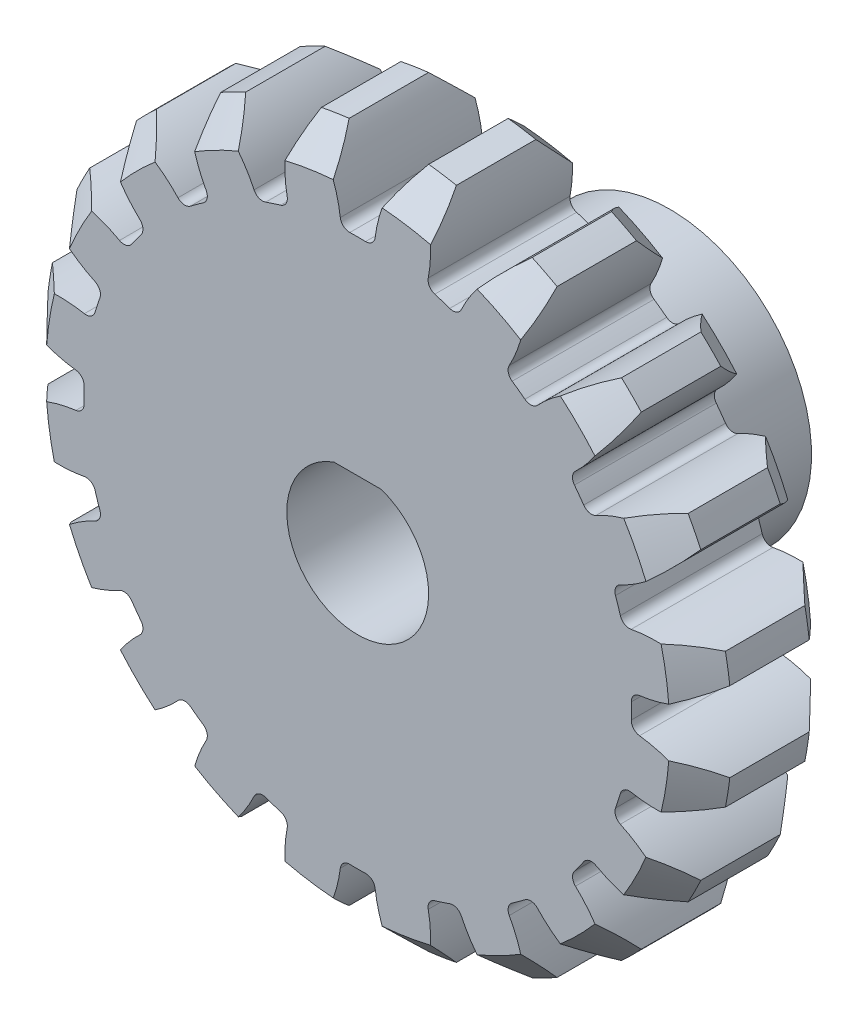
from build123d import *

# Parameters (mm, degrees)
SKETCH1_R                = 24.2
BOSS_EXTRUDE1_DEPTH      = 5
CUT_EXTRUDE1_DEPTH       = 6
FILLET1_R                = 0.66
CHAMFER1_SIZE            = 2.2
CIRPATTERN1_COUNT        = 20
FILLET1_OF_CIRPATTERN1_R = 0.66
CUT_EXTRUDE2_DEPTH       = 11.0000001
FILLET2_R                = 0.2
SKETCH6_R                = 10
BOSS_EXTRUDE2_DEPTH      = 12
BOSS_EXTRUDE2_DEPTH_BACK = 10
SKETCH8_R                = 1.15
CUT_EXTRUDE3_DEPTH       = 12


with BuildPart() as part:
    # Sketch1 → Boss-Extrude1 (new body, symmetric)
    with BuildSketch(Plane.XY):
        Circle(SKETCH1_R)
    extrude(amount=BOSS_EXTRUDE1_DEPTH, both=True)

    # Sketch2 → Cut-Extrude1 (cut, symmetric)
    with BuildSketch(Plane.XY):
        with BuildLine():
            ThreePointArc((2.806060396, 24.03676403), (1.665729243, 21.761247794), (1.171675149, 19.264401816))
            ThreePointArc((1.171675149, 19.264401816), (0, 19.3), (-1.171675149, 19.264401816))
            ThreePointArc((-1.171675149, 19.264401816), (-1.665729243, 21.761247794), (-2.806060396, 24.03676403))
            ThreePointArc((-2.806060396, 24.03676403), (0, 24.2), (2.806060396, 24.03676403))
        make_face()
    cut_extrude1 = extrude(amount=CUT_EXTRUDE1_DEPTH, both=True, mode=Mode.SUBTRACT)

    # Fillet1
    fillet1_edges = [part.edges().sort_by_distance(p)[0] for p in [
        (1.171675149, 19.264401816, 0),
        (-1.171675149, 19.264401816, 0),
    ]]
    fillet(fillet1_edges, radius=FILLET1_R)

    # Chamfer1
    chamfer1_edges = [part.edges().sort_by_distance(p)[0] for p in [
        (0, -24.2, -5),
        (0, -24.2, 5),
    ]]
    chamfer(chamfer1_edges, length=CHAMFER1_SIZE)

    # CirPattern1: Cut-Extrude1 ×20 about axis
    cirpattern1_axis = Axis((0, 0, 0), (0, 0, 1))
    for i in range(1, CIRPATTERN1_COUNT):
        add(cut_extrude1.rotate(cirpattern1_axis, i * 360 / CIRPATTERN1_COUNT), mode=Mode.SUBTRACT)

    # Fillet1 of CirPattern1
    fillet1_of_cirpattern1_edges = [part.edges().sort_by_distance(p)[0] for p in [
        (-4.838698263, 18.683602413, 0),
        (-7.067356833, 17.959467347, 0),
        (-10.375426175, 16.273921829, 0),
        (-12.271236389, 14.896535083, 0),
        (-14.896535083, 12.271236389, 0),
        (-16.273921829, 10.375426175, 0),
        (-17.959467347, 7.067356833, 0),
        (-18.683602413, 4.838698263, 0),
        (-19.264401816, 1.171675149, 0),
        (-19.264401816, -1.171675149, 0),
        (-18.683602413, -4.838698263, 0),
        (-17.959467347, -7.067356833, 0),
        (-16.273921829, -10.375426175, 0),
        (-14.896535083, -12.271236389, 0),
        (-12.271236389, -14.896535083, 0),
        (-10.375426175, -16.273921829, 0),
        (-7.067356833, -17.959467347, 0),
        (-4.838698263, -18.683602413, 0),
        (-1.171675149, -19.264401816, 0),
        (1.171675149, -19.264401816, 0),
        (4.838698263, -18.683602413, 0),
        (7.067356833, -17.959467347, 0),
        (10.375426175, -16.273921829, 0),
        (12.271236389, -14.896535083, 0),
        (14.896535083, -12.271236389, 0),
        (16.273921829, -10.375426175, 0),
        (17.959467347, -7.067356833, 0),
        (18.683602413, -4.838698263, 0),
        (19.264401816, -1.171675149, 0),
        (19.264401816, 1.171675149, 0),
        (18.683602413, 4.838698263, 0),
        (17.959467347, 7.067356833, 0),
        (16.273921829, 10.375426175, 0),
        (14.896535083, 12.271236389, 0),
        (12.271236389, 14.896535083, 0),
        (10.375426175, 16.273921829, 0),
        (7.067356833, 17.959467347, 0),
        (4.838698263, 18.683602413, 0),
    ]]
    fillet(fillet1_of_cirpattern1_edges, radius=FILLET1_OF_CIRPATTERN1_R)

    # Sketch3 → Cut-Extrude2 (cut, through all)
    with BuildSketch(Plane.XY.offset(5)):
        with BuildLine():
            Line((-2, 4.582575695), (-2, 7))
            Line((-2, 7), (2, 7))
            Line((2, 7), (2, 4.582575695))
            ThreePointArc((2, 4.582575695), (0, -5), (-2, 4.582575695))
        make_face()
    extrude(amount=-CUT_EXTRUDE2_DEPTH, mode=Mode.SUBTRACT)

    # Fillet2
    fillet2_edges = [part.edges().sort_by_distance(p)[0] for p in [
        (0, -5, -5),
        (2, 4.582575695, 0),
        (-2, 5.791287847, -5),
        (-2, 4.582575695, 0),
        (0, 7, -5),
        (-2, 7, 0),
        (2, 5.791287847, -5),
        (2, 7, 0),
        (0, -5, 5),
        (2, 5.791287847, 5),
        (0, 7, 5),
        (-2, 5.791287847, 5),
    ]]
    fillet(fillet2_edges, radius=FILLET2_R)

    # Sketch6 → Boss-Extrude2 (add, two sides)
    with BuildSketch(Plane(origin=(0, 0, -5), x_dir=(-1, 0, 0), z_dir=(0, 0, -1))) as boss_extrude2_sk:
        Circle(SKETCH6_R)
        with BuildLine():
            Line((-1.673320053, 4.711687596), (1.673320053, 4.711687596))
            ThreePointArc((1.673320053, 4.711687596), (0, -5), (-1.673320053, 4.711687596))
        make_face(mode=Mode.SUBTRACT)
    extrude(amount=BOSS_EXTRUDE2_DEPTH)
    extrude(boss_extrude2_sk.sketch, amount=-BOSS_EXTRUDE2_DEPTH_BACK)

    # Sketch8 → Cut-Extrude3 (cut)
    with BuildSketch(Plane(origin=(0, 0, 0), x_dir=(1, 0, 0), z_dir=(0, 1, 0))):
        with Locations((0, 11)):
            Circle(SKETCH8_R)
    extrude(amount=CUT_EXTRUDE3_DEPTH, mode=Mode.SUBTRACT)


solid = part.part
